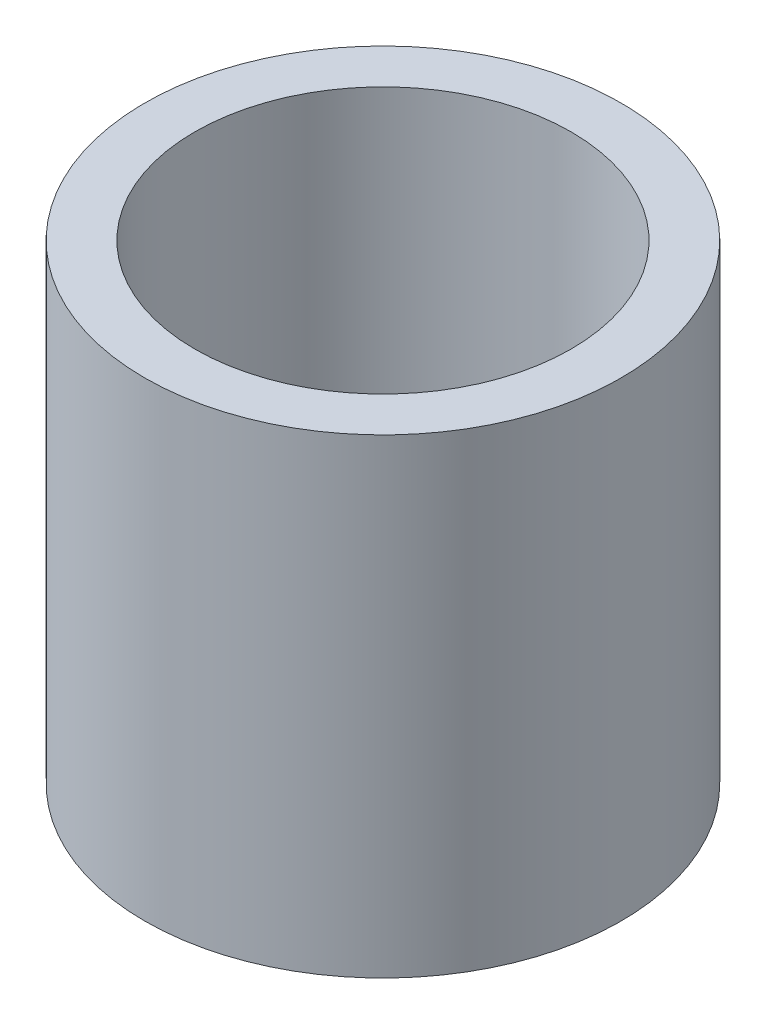
from build123d import *

# Parameters (mm, degrees)
SKETCH1_R           = 10
SKETCH1_R_2         = 7.9
BOSS_EXTRUDE1_DEPTH = 19.75


with BuildPart() as part:
    # Sketch1 → Boss-Extrude1 (new body)
    with BuildSketch(Plane(origin=(0, 0, 0), x_dir=(1, 0, 0), z_dir=(0, 1, 0))):
        Circle(SKETCH1_R)
        Circle(SKETCH1_R_2, mode=Mode.SUBTRACT)
    extrude(amount=BOSS_EXTRUDE1_DEPTH)


solid = part.part
